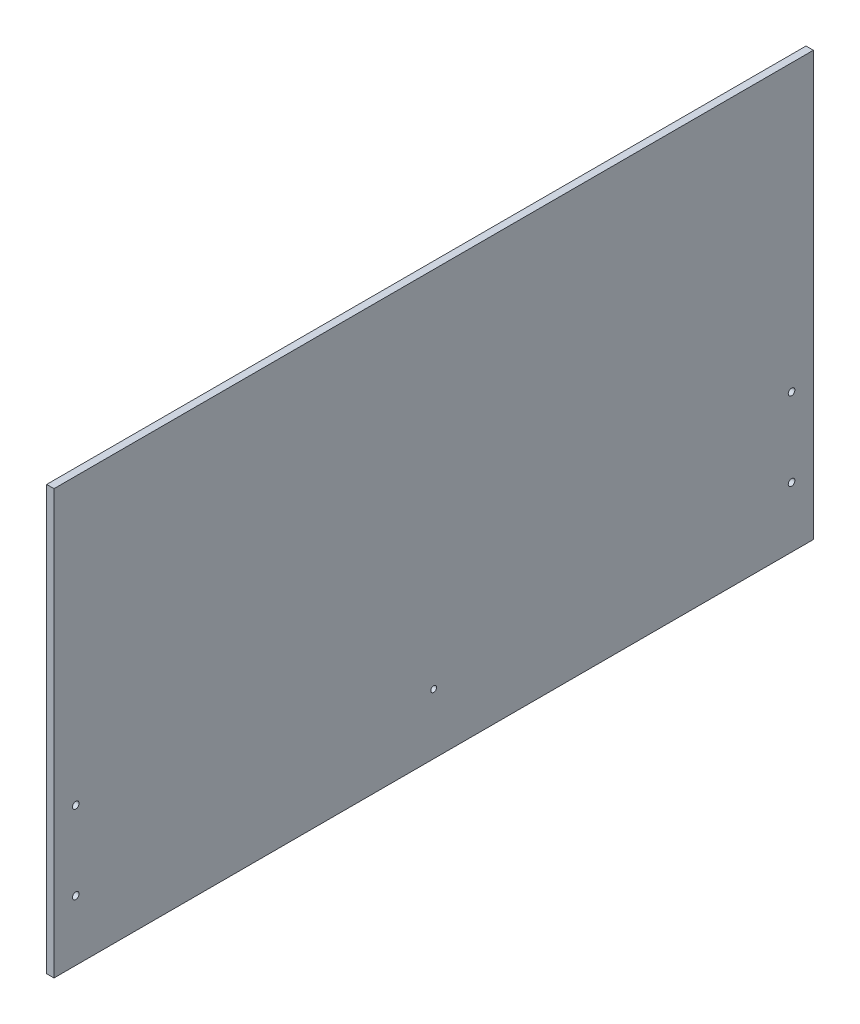
from build123d import *

# Parameters (mm, degrees)
SKETCH1_W                 = 492.125
SKETCH1_H                 = 274.6375
BOSS_EXTRUDE1_DEPTH       = 4.7625
CUT_EXTRUDE1_REACH        = 6.763
BOSS_EXTRUDE2_REACH       = 494.125
SKETCH3_W                 = 4.7625
SKETCH3_H                 = 274.6375
F_8_CLEARANCE_HOLE1_D     = 4.3053
F_8_CLEARANCE_HOLE1_DEPTH = 74.422
F_8_CLEARANCE_HOLE1_TIP   = 1.293442612
F_6_CLEARANCE_HOLE1_D     = 3.7973
F_6_CLEARANCE_HOLE1_DEPTH = 25.4
F_6_CLEARANCE_HOLE1_TIP   = 1.140824014


with BuildPart() as part:
    # Sketch1 → Boss-Extrude1 (new body)
    with BuildSketch(Plane(origin=(0, 0, 0), x_dir=(0, 0, -1), z_dir=(1, 0, 0))):
        Rectangle(SKETCH1_W, SKETCH1_H)
    extrude(amount=BOSS_EXTRUDE1_DEPTH)

    # Sketch2 → Cut-Extrude1 (cut, up to next)
    with BuildSketch(Plane(origin=(4.7625, 0, 0), x_dir=(0, 0, -1), z_dir=(1, 0, 0)), mode=Mode.PRIVATE) as cut_extrude1_sk1:
        Polygon((-24.852813742, -60), (24.852813742, -60), (42.426406871, -42.426406871), (60, -24.852813742), (60, 24.852813742), (24.852813742, 60), (-24.852813742, 60), (-60, 24.852813742), (-60, -24.852813742), align=None)
    cut_extrude1_tool1 = extrude(cut_extrude1_sk1.sketch, amount=-CUT_EXTRUDE1_REACH, mode=Mode.PRIVATE) & part.part
    add(cut_extrude1_tool1.solids().sort_by_distance((4.7625, 0, 0))[0], mode=Mode.SUBTRACT)

    # Sketch3 → Boss-Extrude2 (add, up to next)
    with BuildSketch(Plane.XY.offset(246.0625), mode=Mode.PRIVATE) as boss_extrude2_sk1:
        with Locations((2.38125, 0)):
            Rectangle(SKETCH3_W, SKETCH3_H)
    boss_extrude2_tool1 = extrude(boss_extrude2_sk1.sketch, amount=-BOSS_EXTRUDE2_REACH, mode=Mode.PRIVATE) - part.part
    add(boss_extrude2_tool1.solids().sort_by_distance((2.38125, 0, 246.0625))[0])

    # #8 Clearance Hole1
    with Locations(Plane(origin=(4.7625, 0, 0), x_dir=(0, 0, -1), z_dir=(1, 0, 0))):
        with Locations((-231.93375, -98.20275), (-231.93375, -47.40275), (231.93375, -47.40275), (231.93375, -98.20275)):
            Hole(F_8_CLEARANCE_HOLE1_D / 2, depth=F_8_CLEARANCE_HOLE1_DEPTH)
            with Locations((0, 0, -(F_8_CLEARANCE_HOLE1_DEPTH + F_8_CLEARANCE_HOLE1_TIP / 2))):  # 118° drill point
                Cone(0, F_8_CLEARANCE_HOLE1_D / 2, F_8_CLEARANCE_HOLE1_TIP, mode=Mode.SUBTRACT)

    # #6 Clearance Hole1
    with Locations(Plane(origin=(4.7625, 0, 0), x_dir=(0, 0, -1), z_dir=(1, 0, 0))):
        with Locations((0, -98.20275)):
            Hole(F_6_CLEARANCE_HOLE1_D / 2, depth=F_6_CLEARANCE_HOLE1_DEPTH)
            with Locations((0, 0, -(F_6_CLEARANCE_HOLE1_DEPTH + F_6_CLEARANCE_HOLE1_TIP / 2))):  # 118° drill point
                Cone(0, F_6_CLEARANCE_HOLE1_D / 2, F_6_CLEARANCE_HOLE1_TIP, mode=Mode.SUBTRACT)


solid = part.part
